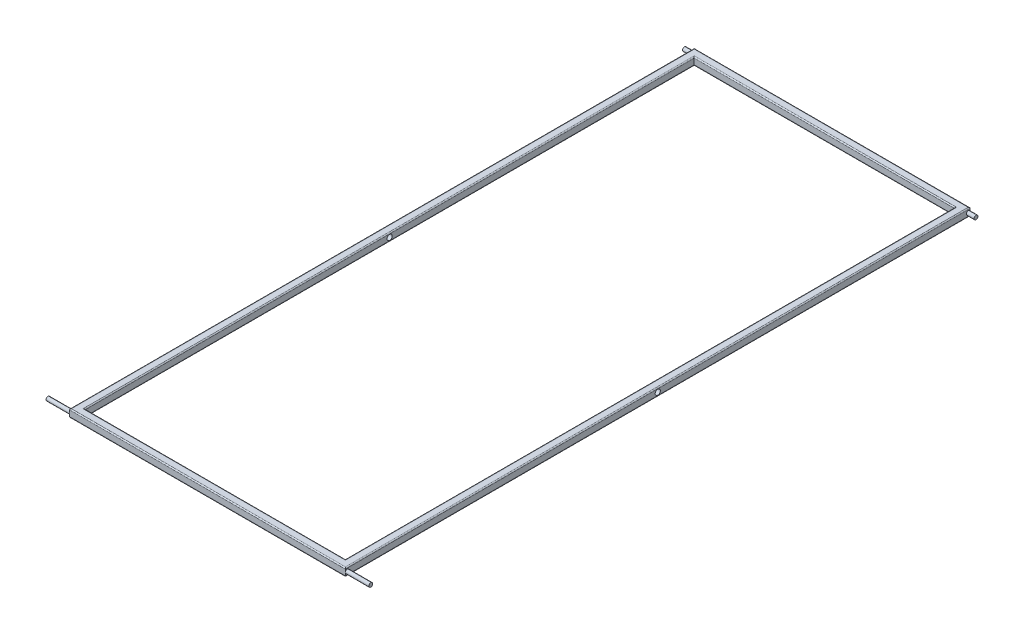
from build123d import *

# Parameters (mm, degrees)
CROQUIS1_W              = 530
CROQUIS1_H              = 1200
CROQUIS1_W_2            = 500
CROQUIS1_H_2            = 1170
SALIENTE_EXTRUIR1_DEPTH = 15
REDONDEO1_R             = 2
REDONDEO2_R             = 2
CROQUIS2_R              = 3.75
SALIENTE_EXTRUIR2_DEPTH = 15
CROQUIS3_R              = 5
CORTAR_EXTRUIR1_DEPTH   = 546
CROQUIS4_R              = 3.75
SALIENTE_EXTRUIR3_DEPTH = 30
CROQUIS5_R              = 3.75
SALIENTE_EXTRUIR4_DEPTH = 30
ESCALA1_SCALE           = 1.3


with BuildPart() as part:
    # Croquis1 → Saliente-Extruir1 (new body)
    with BuildSketch(Plane(origin=(0, 0, 0), x_dir=(1, 0, 0), z_dir=(0, 1, 0))):
        Rectangle(CROQUIS1_W, CROQUIS1_H)
        Rectangle(CROQUIS1_W_2, CROQUIS1_H_2, mode=Mode.SUBTRACT)
    extrude(amount=SALIENTE_EXTRUIR1_DEPTH)

    # Redondeo1
    redondeo1_edges = [part.edges().sort_by_distance(p)[0] for p in [
        (-265, 15, 0),
        (250, 15, 0),
        (0, 15, 600),
        (0, 15, -585),
        (-250, 15, 0),
        (0, 15, 585),
        (265, 15, 0),
        (0, 15, -600),
    ]]
    fillet(redondeo1_edges, radius=REDONDEO1_R)

    # Redondeo2
    redondeo2_edges = [part.edges().sort_by_distance(p)[0] for p in [
        (250, 0, 0),
        (0, 0, -585),
        (-250, 0, 0),
        (0, 0, 585),
        (0, 0, 600),
        (-265, 0, 0),
        (0, 0, -600),
        (265, 0, 0),
    ]]
    fillet(redondeo2_edges, radius=REDONDEO2_R)

    # Croquis2 → Saliente-Extruir2 (add)
    with BuildSketch(Plane.ZY.offset(265)):
        with Locations((596.25, 7.5)):
            Circle(CROQUIS2_R)
        with Locations((-596.25, 7.5)):
            Circle(CROQUIS2_R)
    saliente_extruir2 = extrude(amount=SALIENTE_EXTRUIR2_DEPTH)

    # Simetría1: Saliente-Extruir2 across plane
    add(saliente_extruir2.mirror(Plane(origin=(0, 0, 0), x_dir=(0, 0, 1), z_dir=(1, 0, 0))))

    # Croquis3 → Cortar-Extruir1 (cut, through all)
    with BuildSketch(Plane.ZY.offset(265)):
        with Locations((0, 7.5)):
            Circle(CROQUIS3_R)
    extrude(amount=-CORTAR_EXTRUIR1_DEPTH, mode=Mode.SUBTRACT)

    # Croquis4 → Saliente-Extruir3 (add)
    with BuildSketch(Plane(origin=(280, 0, 0), x_dir=(0, 0, -1), z_dir=(1, 0, 0))):
        with Locations((-596.25, 7.5)):
            Circle(CROQUIS4_R)
    extrude(amount=SALIENTE_EXTRUIR3_DEPTH)

    # Croquis5 → Saliente-Extruir4 (add)
    with BuildSketch(Plane.ZY.offset(280)):
        with Locations((596.25, 7.5)):
            Circle(CROQUIS5_R)
    extrude(amount=SALIENTE_EXTRUIR4_DEPTH)


with BuildPart() as part_1:
    # Escala1: scaled about (0, 0, 0)
    add(part.part.scale(ESCALA1_SCALE))


solid = part_1.part
